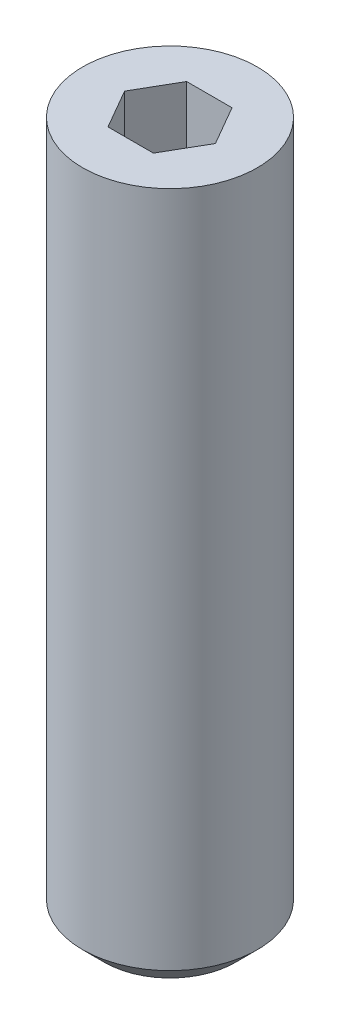
from build123d import *

# Parameters (mm, degrees)
SKETCH1_R           = 1
BOSS_EXTRUDE1_DEPTH = 8
CHAMFER1_SIZE       = 0.25
CUT_EXTRUDE1_DEPTH  = 0.8


with BuildPart() as part:
    # Sketch1 → Boss-Extrude1 (new body)
    with BuildSketch(Plane(origin=(0, 0, 0), x_dir=(1, 0, 0), z_dir=(0, 1, 0))):
        Circle(SKETCH1_R)
    extrude(amount=BOSS_EXTRUDE1_DEPTH)

    # Chamfer1
    chamfer1_edges = [part.edges().sort_by_distance(p)[0] for p in [
        (-1, 0, 0),
    ]]
    chamfer(chamfer1_edges, length=CHAMFER1_SIZE)

    # Sketch2 → Cut-Extrude1 (cut)
    with BuildSketch(Plane(origin=(0, 8, 0), x_dir=(1, 0, 0), z_dir=(0, 1, 0))):
        Polygon((0.259807621, -0.45), (0.519615242, 0), (0.259807621, 0.45), (-0.259807621, 0.45), (-0.519615242, 0), (-0.259807621, -0.45), align=None)
    extrude(amount=-CUT_EXTRUDE1_DEPTH, mode=Mode.SUBTRACT)


solid = part.part
